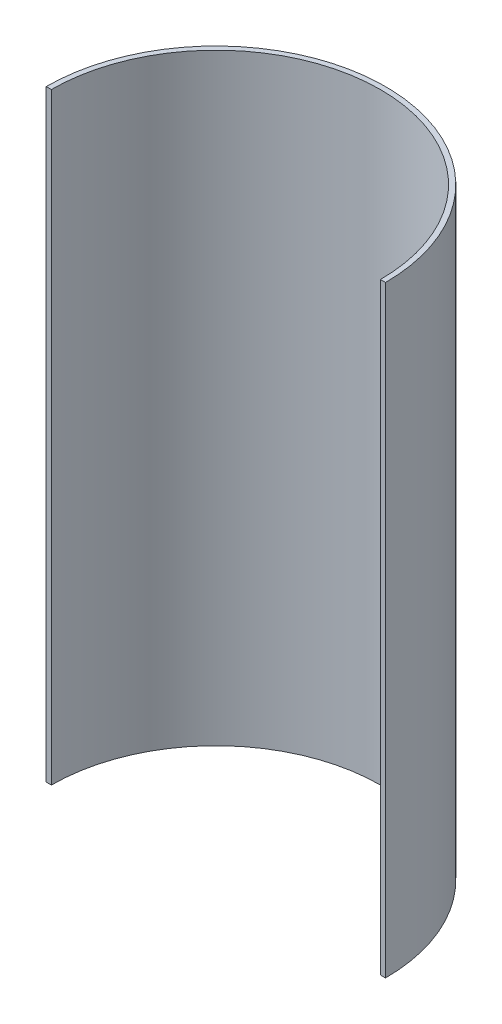
from build123d import *

# Parameters (mm, degrees)
BOSS_EXTRUDE1_DEPTH = 940


with BuildPart() as part:
    # Sketch1 → Boss-Extrude1 (new body)
    with BuildSketch(Plane(origin=(0, 0, 0), x_dir=(1, 0, 0), z_dir=(0, 1, 0))):
        with BuildLine():
            Line((-4, 0), (4, 0))
            ThreePointArc((4, 0), (260.75, 256.75), (517.5, 0))
            Line((517.5, 0), (525.5, 0))
            ThreePointArc((525.5, 0), (260.75, 264.75), (-4, 0))
        make_face()
    extrude(amount=BOSS_EXTRUDE1_DEPTH)


solid = part.part
